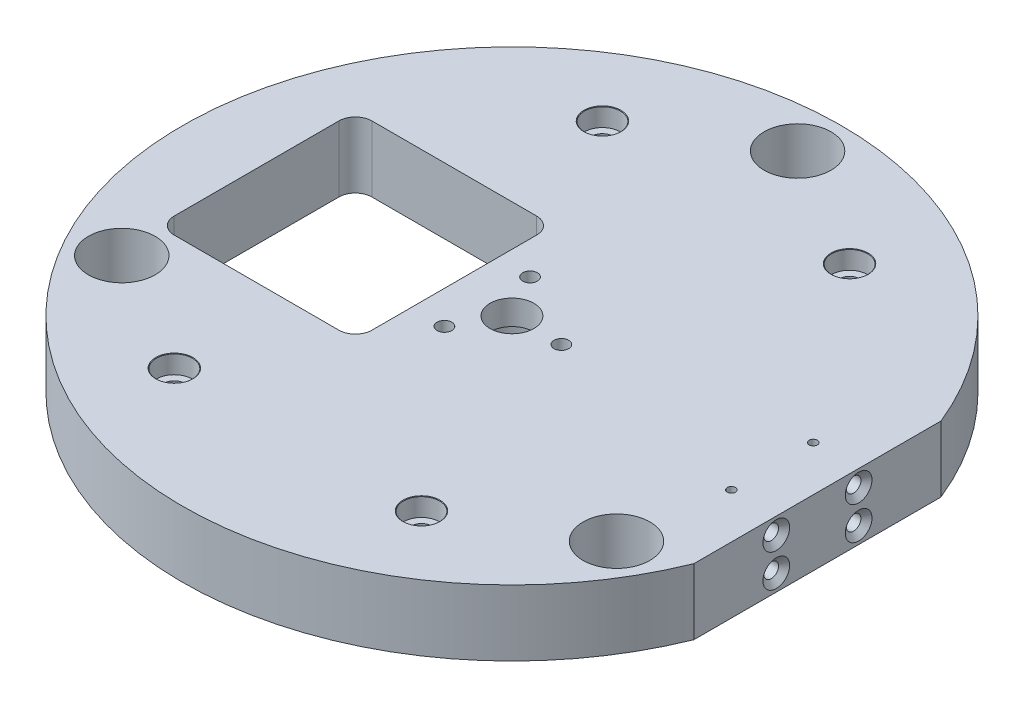
from build123d import *

# Parameters (mm, degrees)
SKETCH1_R                                        = 50.8
BOSS_EXTRUDE1_DEPTH                              = 10.16
SKETCH2_R                                        = 5.15
CUT_EXTRUDE1_DEPTH                               = 11.16
CUT_EXTRUDE10_DEPTH                              = 1
CUT_EXTRUDE10_DEPTH_BACK                         = 11.16
CBORE_FOR_4_SOCKET_HEAD_CAP_SCREW1_AT_2_COUNT    = 2
CBORE_FOR_4_SOCKET_HEAD_CAP_SCREW1_AT_2_PITCH    = 65.991135768
CBORE_FOR_4_SOCKET_HEAD_CAP_SCREW1_AT_3_COUNT    = 2
CBORE_FOR_4_SOCKET_HEAD_CAP_SCREW1_AT_3_PITCH    = 76.2
CBORE_FOR_4_SOCKET_HEAD_CAP_SCREW1_AT_4_COUNT    = 2
CBORE_FOR_4_SOCKET_HEAD_CAP_SCREW1_AT_4_PITCH    = 38.1
CUT_EXTRUDE9_DEPTH                               = 11.16
F_4_40_TAPPED_HOLE1_D                            = 2.2606
CBORE_FOR_1_4_SOCKET_HEAD_CAP_SCREW1_D           = 6.7564
CBORE_FOR_1_4_SOCKET_HEAD_CAP_SCREW1_CBORE_D     = 11.1125
CBORE_FOR_1_4_SOCKET_HEAD_CAP_SCREW1_CBORE_DEPTH = 6.35
F_97_0_0059_DIAMETER_HOLE1_D                     = 1.27
F_4_40_TAPPED_HOLE2_D                            = 2.2606
F_4_40_TAPPED_HOLE2_DEPTH                        = 7.5946
F_4_40_TAPPED_HOLE2_CSINK_D                      = 4.1148
F_4_40_TAPPED_HOLE2_CSINK_ANGLE                  = 100
F_4_40_TAPPED_HOLE2_TIP                          = 0.679152758


with BuildPart() as part:
    # Sketch1 → Boss-Extrude1 (new body)
    with BuildSketch(Plane(origin=(0, 0, 0), x_dir=(1, 0, 0), z_dir=(0, 1, 0))):
        with Locations(Location((0, 0, 0), (0, 0, 270))):  # turned: the seam where the file's is
            Circle(SKETCH1_R)
    extrude(amount=BOSS_EXTRUDE1_DEPTH)

    # Sketch2 → Cut-Extrude1 (cut, through all)
    with BuildSketch(Plane(origin=(0, 10.16, 0), x_dir=(1, 0, 0), z_dir=(0, 1, 0))):
        with Locations(Location((0, 44.02963, 0), (0, 0, 270))):  # turned: the seam where the file's is
            Circle(SKETCH2_R)
        with Locations(Location((38.130778099, -22.014815, 0), (0, 0, 270))):  # turned: the seam where the file's is
            Circle(SKETCH2_R)
        with Locations(Location((-38.130778099, -22.014815, 0), (0, 0, 270))):  # turned: the seam where the file's is
            Circle(SKETCH2_R)
    extrude(amount=-CUT_EXTRUDE1_DEPTH, mode=Mode.SUBTRACT)

    # Sketch46 → Cut-Extrude10 (cut, two sides)
    with BuildSketch(Plane(origin=(0, 10.16, 0), x_dir=(1, 0, 0), z_dir=(0, 1, 0))) as cut_extrude10_sk:
        Polygon((47.092860393, 269.566399573), (47.092860393, 19.05), (47.092860393, -19.05), (47.092860393, -269.566399573), (548.12565954, -269.566399573), (548.12565954, 269.566399573), align=None)
    extrude(amount=CUT_EXTRUDE10_DEPTH, mode=Mode.SUBTRACT)
    extrude(cut_extrude10_sk.sketch, amount=-CUT_EXTRUDE10_DEPTH_BACK, mode=Mode.SUBTRACT)

    # Sketch38 → CBORE for #4 Socket Head Cap Screw1 (revolve, cut)
    with BuildSketch(Plane(origin=(19.05, 10.16, -32.995567884), x_dir=(0, 0, 1), z_dir=(1, 0, 0))):
        Polygon((0, 0), (0, 10.16), (1.63195, 10.16), (1.63195, 2.8448), (2.77876, 2.8448), (2.77876, 0.066070705), (2.8575, 0), align=None)
    cbore_for_4_socket_head_cap_screw1 = revolve(axis=Axis((19.05, 16.51, -32.995567884), (0, -1, 0)), mode=Mode.SUBTRACT)

    # CBORE for #4 Socket Head Cap Screw1 at 2: CBORE for #4 Socket Head Cap Screw1 ×2
    with Locations(*[(0, 0, i * CBORE_FOR_4_SOCKET_HEAD_CAP_SCREW1_AT_2_PITCH) for i in range(1, CBORE_FOR_4_SOCKET_HEAD_CAP_SCREW1_AT_2_COUNT)]):
        add(cbore_for_4_socket_head_cap_screw1, mode=Mode.SUBTRACT)

    # CBORE for #4 Socket Head Cap Screw1 at 3: CBORE for #4 Socket Head Cap Screw1 ×2
    with Locations(*[Vector(-0.5, 0, 0.866025404) * (i * CBORE_FOR_4_SOCKET_HEAD_CAP_SCREW1_AT_3_PITCH) for i in range(1, CBORE_FOR_4_SOCKET_HEAD_CAP_SCREW1_AT_3_COUNT)]):
        add(cbore_for_4_socket_head_cap_screw1, mode=Mode.SUBTRACT)

    # CBORE for #4 Socket Head Cap Screw1 at 4: CBORE for #4 Socket Head Cap Screw1 ×2
    with Locations(*[(-i * CBORE_FOR_4_SOCKET_HEAD_CAP_SCREW1_AT_4_PITCH, 0, 0) for i in range(1, CBORE_FOR_4_SOCKET_HEAD_CAP_SCREW1_AT_4_COUNT)]):
        add(cbore_for_4_socket_head_cap_screw1, mode=Mode.SUBTRACT)

    # Sketch39 → Cut-Extrude9 (cut, through all)
    with BuildSketch(Plane(origin=(0, 10.16, 0), x_dir=(1, 0, 0), z_dir=(0, 1, 0))):
        with BuildLine():
            Line((-39.37, 12.7), (-39.37, -12.7))
            ThreePointArc((-39.37, -12.7), (-38.626051224, -14.496051224), (-36.83, -15.24))
            Line((-36.83, -15.24), (-11.43, -15.24))
            ThreePointArc((-11.43, -15.24), (-9.633948776, -14.496051224), (-8.89, -12.7))
            Line((-8.89, -12.7), (-8.89, 12.7))
            ThreePointArc((-8.89, 12.7), (-9.633948776, 14.496051224), (-11.43, 15.24))
            Line((-11.43, 15.24), (-36.83, 15.24))
            ThreePointArc((-36.83, 15.24), (-38.626051224, 14.496051224), (-39.37, 12.7))
        make_face()
    extrude(amount=-CUT_EXTRUDE9_DEPTH, mode=Mode.SUBTRACT)

    # #4-40 Tapped Hole1 (through all)
    with Locations(Plane(origin=(0, 10.16, 0), x_dir=(1, 0, 0), z_dir=(0, 1, 0))):
        with Locations((7.62, 0), (-3.81, -6.599113577), (-3.81, 6.599113577)):
            Hole(F_4_40_TAPPED_HOLE1_D / 2)

    # CBORE for 1/4 Socket Head Cap Screw1 (through all)
    with Locations(Plane(origin=(0, 0, 0), x_dir=(-1, 0, 0), z_dir=(0, -1, 0))):
        with Locations((0, 0)):
            CounterBoreHole(CBORE_FOR_1_4_SOCKET_HEAD_CAP_SCREW1_D / 2, CBORE_FOR_1_4_SOCKET_HEAD_CAP_SCREW1_CBORE_D / 2, CBORE_FOR_1_4_SOCKET_HEAD_CAP_SCREW1_CBORE_DEPTH)

    # #97 (0.0059) Diameter Hole1 (through all)
    with Locations(Plane(origin=(0, 10.16, 0), x_dir=(1, 0, 0), z_dir=(0, 1, 0))):
        with Locations((40.132, 6.310189161), (40.132, -6.310189161)):
            Hole(F_97_0_0059_DIAMETER_HOLE1_D / 2)

    # #4-40 Tapped Hole2
    with Locations(Plane(origin=(47.092860393, 0, 0), x_dir=(0, 0, -1), z_dir=(1, 0, 0))):
        with Locations((-6.35, 7.62), (-6.35, 2.54), (6.35, 7.62), (6.35, 2.54)):
            CounterSinkHole(F_4_40_TAPPED_HOLE2_D / 2, F_4_40_TAPPED_HOLE2_CSINK_D / 2, depth=F_4_40_TAPPED_HOLE2_DEPTH, counter_sink_angle=F_4_40_TAPPED_HOLE2_CSINK_ANGLE)
            with Locations((0, 0, -(F_4_40_TAPPED_HOLE2_DEPTH + F_4_40_TAPPED_HOLE2_TIP / 2))):  # 118° drill point
                Cone(0, F_4_40_TAPPED_HOLE2_D / 2, F_4_40_TAPPED_HOLE2_TIP, mode=Mode.SUBTRACT)


solid = part.part
